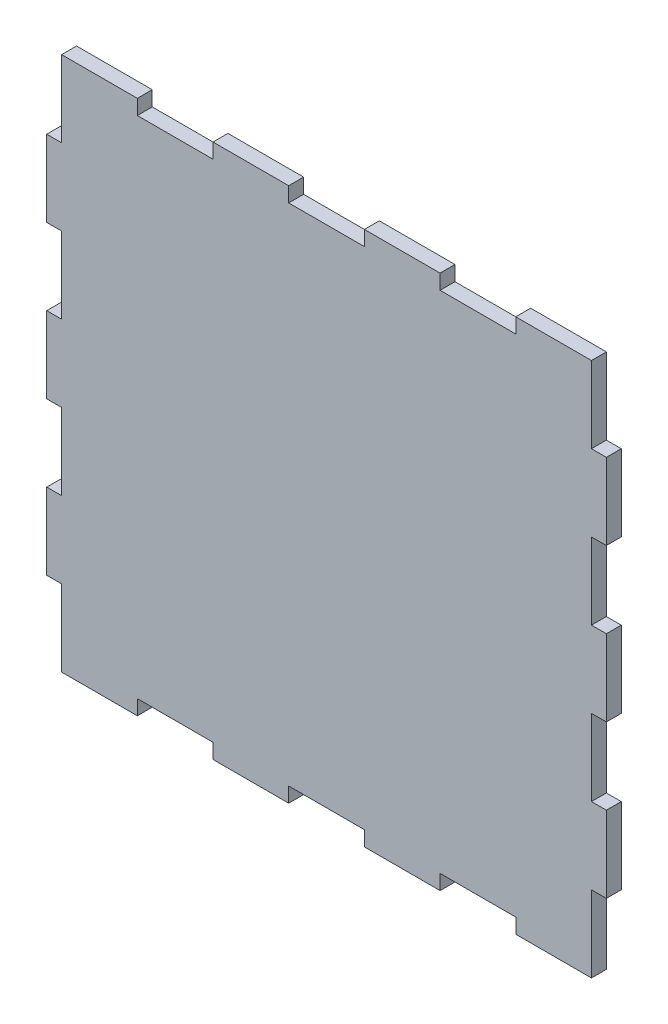
from build123d import *

# Parameters (mm, degrees)
SALIENTE_EXTRUIR1_DEPTH = 3


with BuildPart() as part:
    # Croquis1 → Saliente-Extruir1 (new body)
    with BuildSketch(Plane.XY):
        Polygon((-76.15, 211.332256054), (-76.15, 195.959398911), (-79.15, 195.959398911), (-79.15, 180.586541769), (-76.15, 180.586541769), (-76.15, 165.213684626), (-79.15, 165.213684626), (-79.15, 149.840827483), (-76.15, 149.840827483), (-76.15, 134.46797034), (-79.15, 134.46797034), (-79.15, 119.095113197), (-76.15, 119.095113197), (-76.15, 106.722256054), (-76.15, 103.722256054), (-60.92, 103.722256054), (-60.92, 106.722256054), (-45.69, 106.722256054), (-45.69, 103.722256054), (-30.46, 103.722256054), (-30.46, 106.722256054), (-15.23, 106.722256054), (-15.23, 103.722256054), (0, 103.722256054), (0, 106.722256054), (15.23, 106.722256054), (15.23, 103.722256054), (30.46, 103.722256054), (30.46, 106.722256054), (30.46, 119.095113197), (33.46, 119.095113197), (33.46, 134.46797034), (30.46, 134.46797034), (30.46, 149.840827483), (33.46, 149.840827483), (33.46, 165.213684626), (30.46, 165.213684626), (30.46, 180.586541769), (33.46, 180.586541769), (33.46, 195.959398911), (30.46, 195.959398911), (30.46, 211.332256054), (15.23, 211.332256054), (15.23, 208.332256054), (0, 208.332256054), (0, 211.332256054), (-15.23, 211.332256054), (-15.23, 208.332256054), (-30.46, 208.332256054), (-30.46, 211.332256054), (-45.69, 211.332256054), (-45.69, 208.332256054), (-60.92, 208.332256054), (-60.92, 211.332256054), align=None)
    extrude(amount=SALIENTE_EXTRUIR1_DEPTH)


solid = part.part
